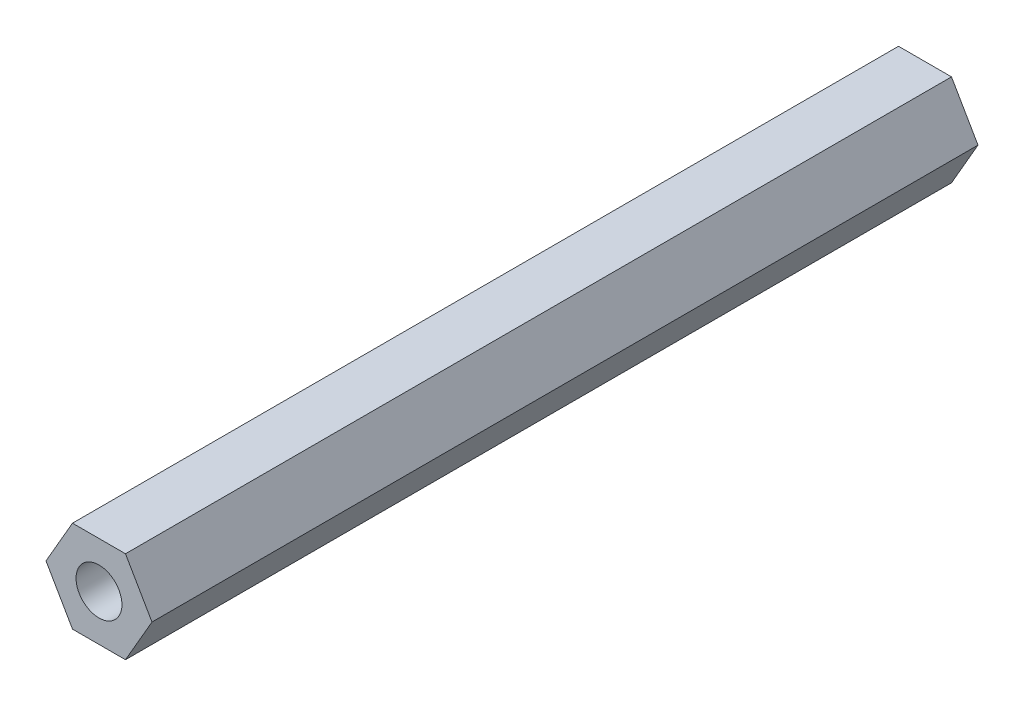
from build123d import *

# Parameters (mm, degrees)
EXTRUDE_1_DEPTH    = 45
HOLE_WIZARD_M3_1_D = 2.5


with BuildPart() as part:
    # 草图1 → 凸台-拉伸1 (new body)
    with BuildSketch(Plane.XY):
        Polygon((1.443375673, 2.5), (-1.443375673, 2.5), (-2.886751346, 0), (-1.443375673, -2.5), (1.443375673, -2.5), (2.886751346, 0), align=None)
    extrude(amount=EXTRUDE_1_DEPTH)

    # M3 螺纹孔1 (through all)
    with Locations(Plane.XY.offset(45)):
        with Locations((0, 0)):
            Hole(HOLE_WIZARD_M3_1_D / 2)


solid = part.part
